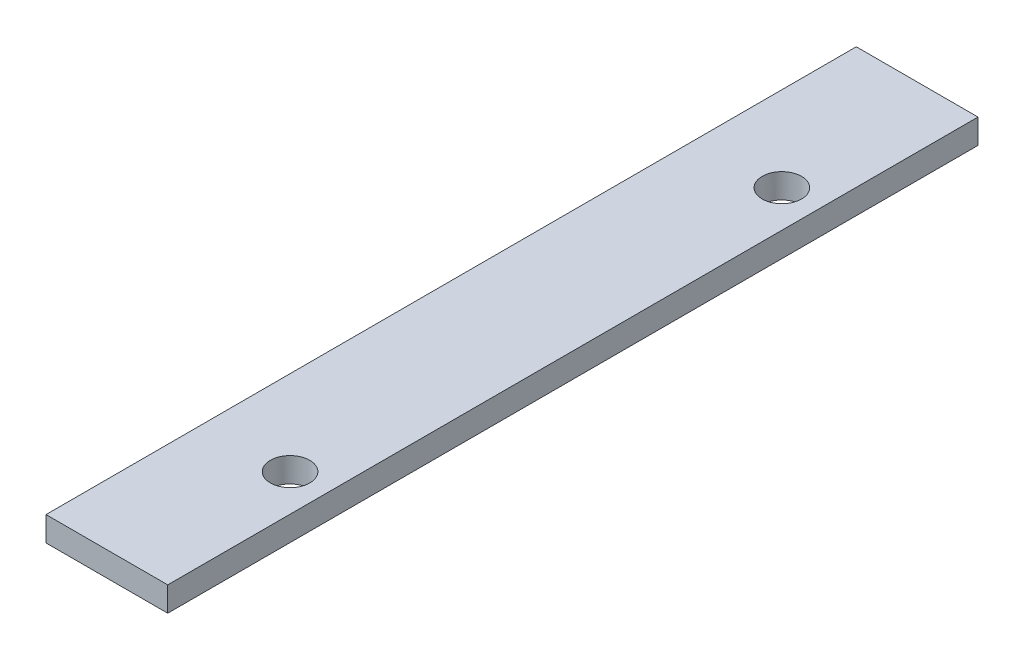
from build123d import *

# Parameters (mm, degrees)
SKETCH_1_W               = 9.9
SKETCH_1_H               = 65.9
EXTRUDE_1_DEPTH          = 2
SKETCH_2_R               = 1.6
CUT_EXTRUDE_1_DEPTH      = 1
CUT_EXTRUDE_1_DEPTH_BACK = 3


with BuildPart() as part:
    # Эскиз1 → Бобышка-Вытянуть1 (new body)
    with BuildSketch(Plane(origin=(0, 0, 0), x_dir=(1, 0, 0), z_dir=(0, 1, 0))):
        Rectangle(SKETCH_1_W, SKETCH_1_H)
    extrude(amount=EXTRUDE_1_DEPTH)

    # Эскиз2 → Вырез-Вытянуть1 (cut, two sides)
    with BuildSketch(Plane(origin=(0, 2, 0), x_dir=(1, 0, 0), z_dir=(0, 1, 0))) as cut_extrude_1_sk:
        with Locations((1.95, 20)):
            Circle(SKETCH_2_R)
        with Locations((1.95, -20)):
            Circle(SKETCH_2_R)
    extrude(amount=CUT_EXTRUDE_1_DEPTH, mode=Mode.SUBTRACT)
    extrude(cut_extrude_1_sk.sketch, amount=-CUT_EXTRUDE_1_DEPTH_BACK, mode=Mode.SUBTRACT)


solid = part.part
